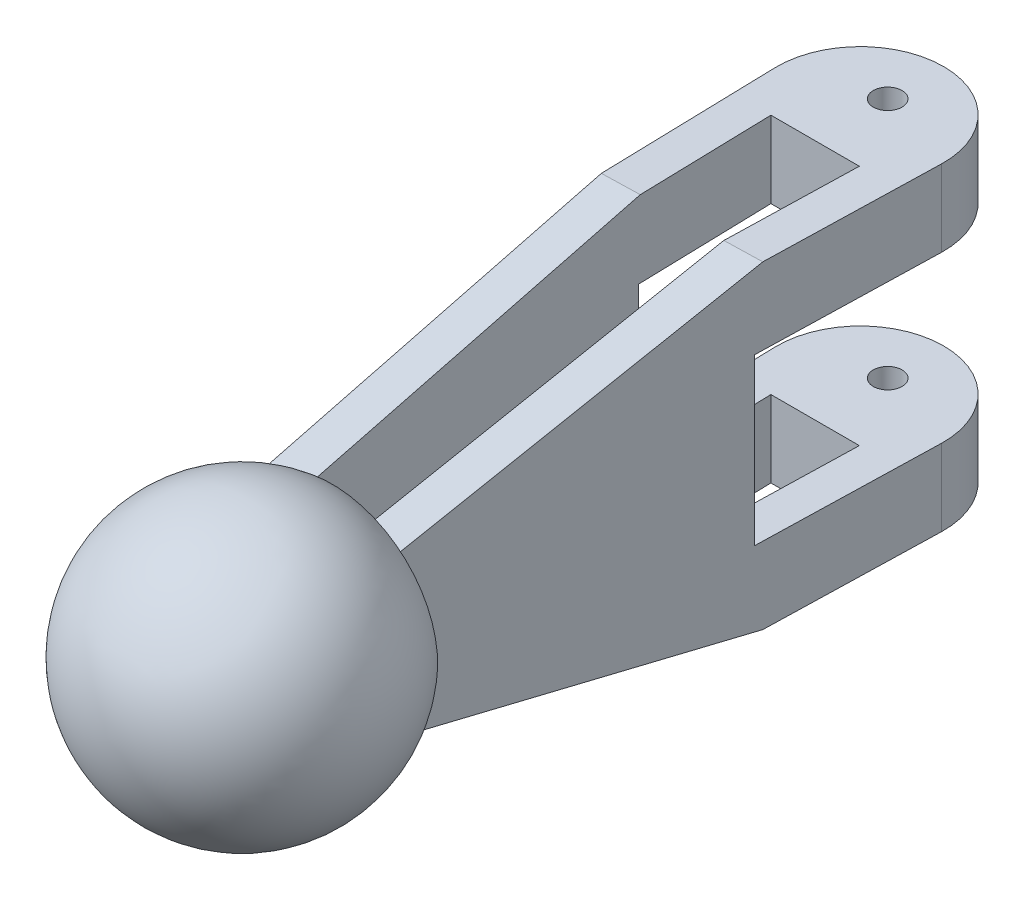
from build123d import *

# Parameters (mm, degrees)
BOSS_EXTRUDE1_DEPTH     = 53.34
SKETCH4_W               = 61.072672184
SKETCH4_H               = 27.686
CUT_EXTRUDE3_DEPTH      = 125.557157077
SKETCH5_OUTSIDE_W       = 57.352
SKETCH5_OUTSIDE_H       = 152.814
CUT_EXTRUDE5_DEPTH      = 123.51837945
SKETCH6_R               = 2.413
CUT_EXTRUDE6_DEPTH      = 123.51837945
CUT_EXTRUDE8_DEPTH      = 100
CUT_EXTRUDE8_DEPTH_BACK = 100
CUT_EXTRUDE9_DEPTH      = 100


with BuildPart() as part:
    # Sketch1 → Boss-Extrude1 (new body)
    with BuildSketch(Plane(origin=(0, 0, 0), x_dir=(1, 0, 0), z_dir=(0, 1, 0))):
        with BuildLine():
            Line((-13.944778991, -0.365156889), (-11.616850564, -89.265156889))
            ThreePointArc((-11.616850564, -89.265156889), (0, -109.412099434), (11.616850564, -89.265156889))
            Line((11.616850564, -89.265156889), (13.944778991, -0.365156889))
            ThreePointArc((13.944778991, -0.365156889), (0, 13.949559157), (-13.944778991, -0.365156889))
        make_face()
    extrude(amount=BOSS_EXTRUDE1_DEPTH)

    # Sketch4 → Cut-Extrude3 (cut, through all)
    with BuildSketch(Plane(origin=(13.944778991, 0, 0.365156889), x_dir=(0.026176948307873094, 0, -0.9996573249755574), z_dir=(0.9996573249755573, 0, 0.02617694830787309))):
        with Locations((0, 26.67)):
            Rectangle(SKETCH4_W, SKETCH4_H)
    extrude(amount=-CUT_EXTRUDE3_DEPTH, mode=Mode.SUBTRACT)

    # Sketch5 outside → Cut-Extrude5 (cut, through all)
    # profile 1 of 2: a face of its own
    with BuildSketch(Plane(origin=(0, 53.34, 0), x_dir=(1, 0, 0), z_dir=(0, 1, 0))):
        with Locations((0, -47.731)):
            Rectangle(SKETCH5_OUTSIDE_W, SKETCH5_OUTSIDE_H)
        with BuildLine():
            Line((-13.944778991, -0.365156889), (-11.616850564, -89.265156889))
            ThreePointArc((-11.616850564, -89.265156889), (0, -109.412099434), (11.616850564, -89.265156889))
            Line((11.616850564, -89.265156889), (13.944778991, -0.365156889))
            ThreePointArc((13.944778991, -0.365156889), (0, 13.949559157), (-13.944778991, -0.365156889))
        make_face(mode=Mode.SUBTRACT)
    # profile 2 of 2: a face of its own
    with BuildSketch(Plane(origin=(0, 53.34, 0), x_dir=(1, 0, 0), z_dir=(0, 1, 0))):
        with BuildLine():
            Line((7.403977553, -7.568443783), (5.213735587, -91.210409969))
            ThreePointArc((5.213735587, -91.210409969), (0, -105.33899845), (-5.213735587, -91.210409969))
            Line((-5.213735587, -91.210409969), (-7.403977553, -7.568443783))
            Line((-7.403977553, -7.568443783), (7.403977553, -7.568443783))
        make_face()
    extrude(amount=-CUT_EXTRUDE5_DEPTH, mode=Mode.SUBTRACT)

    # Sketch6 → Cut-Extrude6 (cut, through all)
    with BuildSketch(Plane(origin=(0, 53.34, 0), x_dir=(1, 0, 0), z_dir=(0, 1, 0))):
        with Locations((0, 4.57874024)):
            Circle(SKETCH6_R)
    extrude(amount=-CUT_EXTRUDE6_DEPTH, mode=Mode.SUBTRACT)

    # Sketch7 → Cut-Extrude8 (cut, two sides: drawn at the far end of the back side and taken through both)
    with BuildSketch(Plane(origin=(-13.944778991, 0, 0.365156889), x_dir=(0.02617694830787368, 0, 0.9996573249755574), z_dir=(-0.9996573249755574, 0, 0.02617694830787368)).offset(-CUT_EXTRUDE8_DEPTH_BACK)):
        Polygon((138.702727396, 53.34), (29.847177093, 53.34), (88.930474252, 40.09), (115.196693912, 40.09), (115.196693912, 13.25), (88.930474252, 13.25), (29.847177093, 0), (138.702727396, 0), align=None)
    extrude(amount=CUT_EXTRUDE8_DEPTH + CUT_EXTRUDE8_DEPTH_BACK, mode=Mode.SUBTRACT)

    # Sketch8 → Cut-Extrude9 (cut)
    with BuildSketch(Plane(origin=(0, 40.09, 0), x_dir=(1, 0, 0), z_dir=(0, 1, 0))):
        Polygon((-11.616850564, -89.265156889), (19.748470708, -88.443827046), (21.136276119, -119.73242467), (-27.769338844, -116.21935592), (-20.465853811, -89.265156889), align=None)
    extrude(amount=-CUT_EXTRUDE9_DEPTH, mode=Mode.SUBTRACT)

    # Sketch14 → Revolve6 (revolve)
    with BuildSketch(Plane(origin=(0, 26.771336555, 0), x_dir=(-0.9996573249755574, 0, 0.02617694830787441), z_dir=(0, 1, 0))):
        with BuildLine():
            Line((2.320752522, 88.930474252), (13.949559157, 88.930474252))
            Line((13.949559157, 88.930474252), (20.039899636, 88.930474252))
            ThreePointArc((20.039899636, 88.930474252), (24.11470465, 95.938974296), (25.530552865, 103.921360067))
            ThreePointArc((25.530552865, 103.921360067), (18.732559735, 120.33316728), (2.320752522, 127.13116041))
            Line((2.320752522, 127.13116041), (2.320752522, 103.921360067))
            Line((2.320752522, 103.921360067), (2.320752522, 88.930474252))
        make_face()
    revolve(axis=Axis((0.400386812, 26.771336555, 103.946499032), (0.026176948307874422, 0, 0.9996573249755573)))


solid = part.part
